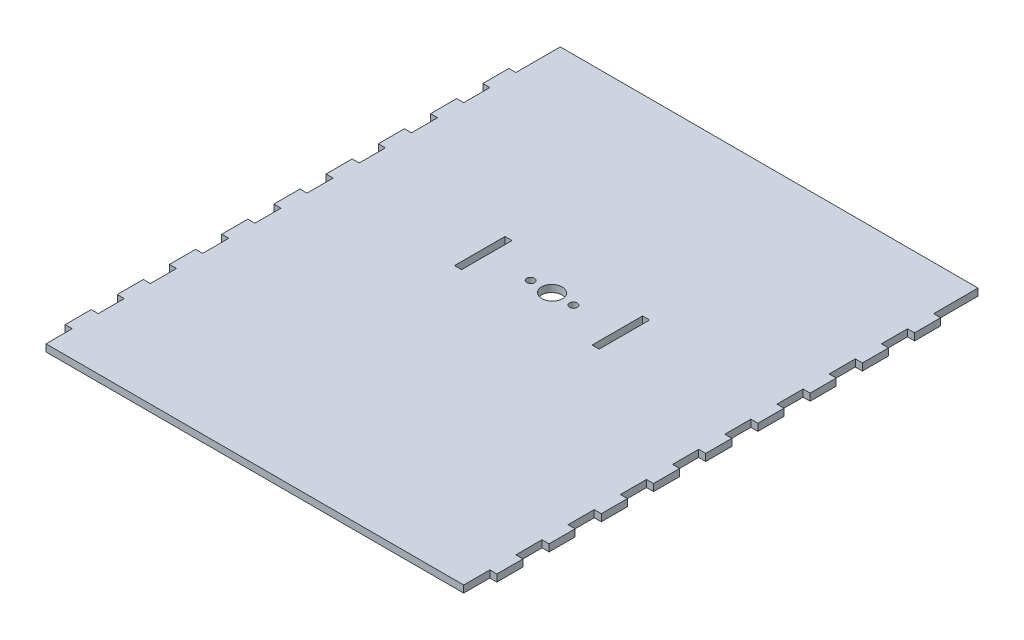
from build123d import *

# Parameters (mm, degrees)
BOSS_EXTRUDE2_DEPTH = 2.7
SKETCH2_RX          = 1.5
SKETCH2_RY          = 1.448888739
SKETCH2_RX_2        = 4
SKETCH2_RY_2        = 3.863703305
SKETCH2_W           = 2.7
SKETCH2_H           = 19.318516525
CUT_EXTRUDE1_DEPTH  = 3


with BuildPart() as part:
    # Sketch1 → Boss-Extrude2 (new body)
    with BuildSketch(Plane(origin=(0, 0, 0), x_dir=(1, 0, 0), z_dir=(0, 1, 0))):
        Polygon((-80, -98.5), (80, -98.5), (80, -88.5), (82.7, -88.5), (82.7, -78.5), (80, -78.5), (80, -68.5), (82.7, -68.5), (82.7, -58.5), (80, -58.5), (80, -48.5), (82.7, -48.5), (82.7, -38.5), (80, -38.5), (80, -28.5), (82.7, -28.5), (82.7, -18.5), (80, -18.5), (80, -8.5), (82.7, -8.5), (82.7, 1.5), (80, 1.5), (80, 11.5), (82.7, 11.5), (82.7, 21.5), (80, 21.5), (80, 31.5), (82.7, 31.5), (82.7, 41.5), (80, 41.5), (80, 51.5), (82.7, 51.5), (82.7, 61.5), (80, 61.5), (80, 71.5), (82.7, 71.5), (82.7, 81.5), (80, 81.5), (80, 98.5), (-80, 98.5), (-80, 81.5), (-82.7, 81.5), (-82.7, 71.5), (-80, 71.5), (-80, 61.5), (-82.7, 61.5), (-82.7, 51.5), (-80, 51.5), (-80, 41.5), (-82.7, 41.5), (-82.7, 31.5), (-80, 31.5), (-80, 21.5), (-82.7, 21.5), (-82.7, 11.5), (-80, 11.5), (-80, 1.5), (-82.7, 1.5), (-82.7, -8.5), (-80, -8.5), (-80, -18.5), (-82.7, -18.5), (-82.7, -28.5), (-80, -28.5), (-80, -38.5), (-82.7, -38.5), (-82.7, -48.5), (-80, -48.5), (-80, -58.5), (-82.7, -58.5), (-82.7, -68.5), (-80, -68.5), (-80, -78.5), (-82.7, -78.5), (-82.7, -88.5), (-80, -88.5), align=None)
    extrude(amount=BOSS_EXTRUDE2_DEPTH)

    # Sketch2 → Cut-Extrude1 (cut)
    with BuildSketch(Plane(origin=(0, 2.7, 0), x_dir=(1, 0, 0), z_dir=(0, 1, 0))):
        with Locations((8.1925, 15.347700679)):
            Ellipse(SKETCH2_RX, SKETCH2_RY)
        with Locations((0, 15.347700679)):
            Ellipse(SKETCH2_RX_2, SKETCH2_RY_2)
        with Locations(Location((-8.1925, 15.347700679), (0, 0, 180))):
            Ellipse(SKETCH2_RX, SKETCH2_RY)
        with Locations((26.35, 15.347700679)):
            Rectangle(SKETCH2_W, SKETCH2_H)
        with Locations((-26.35, 15.347700679)):
            Rectangle(SKETCH2_W, SKETCH2_H)
    extrude(amount=-CUT_EXTRUDE1_DEPTH, mode=Mode.SUBTRACT)


solid = part.part
